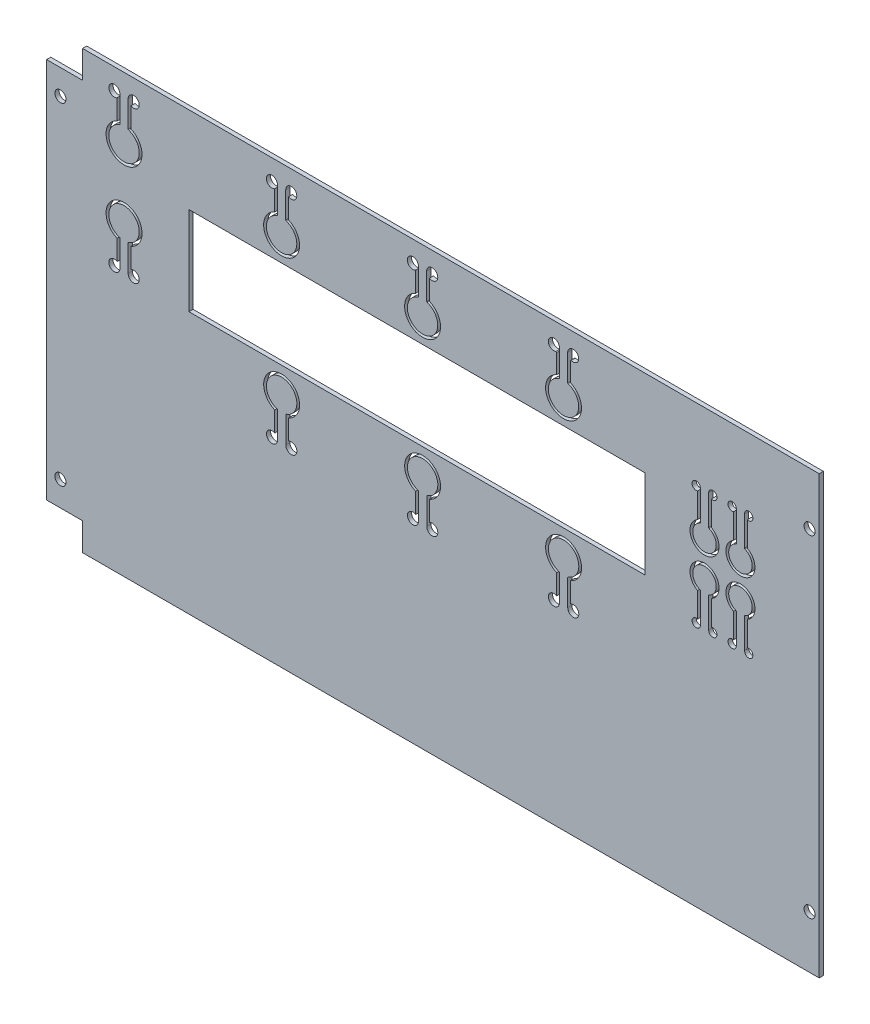
from build123d import *

# Parameters (mm, degrees)
RESSALTO_EXTRUS_O1_DEPTH = 1.5
CORTE_EXTRUS_O1_DEPTH    = 10
ESBO_O2_R                = 2
CORTE_EXTRUS_O2_DEPTH    = 2.5
FILETE1_R                = 0.25


with BuildPart() as part:
    # Model → Ressalto-extrusão1 (new body)
    with BuildSketch(Plane.XY):
        Polygon((22.046079585, 30.361653435), (22.058586918, 22.36166321), (288.058586918, 22.36166321), (288.058586918, 196.36166321), (22.058586918, 196.36166321), (22.058586918, 188.36166321), (12.058586918, 188.36166321), (12.058586918, 178.36166321), (4.058586918, 178.36166321), (4.058586918, 40.36166321), (12.058586918, 40.36166321), (12.046079585, 30.361671032), align=None)
        with BuildLine():
            ThreePointArc((35.057116656, 126.111663212), (31.325065848, 125.111663212), (34.057116656, 127.84371402))
            Line((34.057116656, 127.84371402), (34.057116656, 135.111663212))
            ThreePointArc((34.057116656, 135.111663212), (30.184182589, 142.390612542), (36.565672252, 147.611657582))
            ThreePointArc((36.565672252, 147.611657582), (42.94897806, 142.381529251), (39.057116656, 135.10456215))
            Line((39.057116656, 135.10456215), (39.057116656, 127.84371402))
            ThreePointArc((39.057116656, 127.84371402), (41.057116656, 127.84371402), (42.057116656, 126.111663212))
            ThreePointArc((42.057116656, 126.111663212), (40.057116656, 124.111663212), (38.057116656, 126.111663212))
            Line((38.057116656, 126.111663212), (38.057116656, 135.82016059))
            ThreePointArc((38.057116656, 135.82016059), (36.557116656, 146.611663212), (35.057116656, 135.82016059))
            Line((35.057116656, 135.82016059), (35.057116656, 126.111663212))
        make_face(mode=Mode.SUBTRACT)
        with BuildLine():
            Line((96.078534187, 109.861663212), (96.078534187, 102.59371402))
            ThreePointArc((96.078534187, 102.59371402), (98.078534187, 102.59371402), (99.078534187, 100.861663212))
            ThreePointArc((99.078534187, 100.861663212), (97.078534187, 98.861663212), (95.078534187, 100.861663212))
            Line((95.078534187, 100.861663212), (95.078534187, 110.57016059))
            ThreePointArc((95.078534187, 110.57016059), (93.578534187, 121.361663212), (92.078534187, 110.57016059))
            Line((92.078534187, 110.57016059), (92.078534187, 100.861663212))
            ThreePointArc((92.078534187, 100.861663212), (88.346483379, 99.861663212), (91.078534187, 102.59371402))
            Line((91.078534187, 102.59371402), (91.078534187, 109.861663212))
            ThreePointArc((91.078534187, 109.861663212), (93.578534187, 122.361663212), (96.078534187, 109.861663212))
        make_face(mode=Mode.SUBTRACT)
        with BuildLine():
            Line((147.078534187, 109.861663212), (147.078534187, 102.59371402))
            ThreePointArc((147.078534187, 102.59371402), (149.078534187, 102.59371402), (150.078534187, 100.861663212))
            ThreePointArc((150.078534187, 100.861663212), (148.078534187, 98.861663212), (146.078534187, 100.861663212))
            Line((146.078534187, 100.861663212), (146.078534187, 110.57016059))
            ThreePointArc((146.078534187, 110.57016059), (144.578534187, 121.361663212), (143.078534187, 110.57016059))
            Line((143.078534187, 110.57016059), (143.078534187, 100.861663212))
            ThreePointArc((143.078534187, 100.861663212), (139.346483379, 99.861663212), (142.078534187, 102.59371402))
            Line((142.078534187, 102.59371402), (142.078534187, 109.861663212))
            ThreePointArc((142.078534187, 109.861663212), (144.578534187, 122.361663212), (147.078534187, 109.861663212))
        make_face(mode=Mode.SUBTRACT)
        Polygon((225.058586918, 140.861663212), (225.058586918, 125.111663212), (60.058586918, 125.111663212), (60.058586918, 153.486663212), (60.058586918, 157.111663212), (225.058586918, 157.111663212), align=None, mode=Mode.SUBTRACT)
        with BuildLine():
            ThreePointArc((35.057116656, 171.153165835), (36.557116656, 160.361663212), (38.057116656, 171.153165835))
            Line((38.057116656, 171.153165835), (38.057116656, 180.861663212))
            ThreePointArc((38.057116656, 180.861663212), (40.057116656, 182.861663212), (42.057116656, 180.861663212))
            ThreePointArc((42.057116656, 180.861663212), (41.057116656, 179.129612405), (39.057116656, 179.129612405))
            Line((39.057116656, 179.129612405), (39.057116656, 171.861663212))
            ThreePointArc((39.057116656, 171.861663212), (36.557116656, 159.361663212), (34.057116656, 171.861663212))
            Line((34.057116656, 171.861663212), (34.057116656, 179.129612405))
            ThreePointArc((34.057116656, 179.129612405), (31.325065848, 181.861663212), (35.057116656, 180.861663212))
            Line((35.057116656, 180.861663212), (35.057116656, 171.153165835))
        make_face(mode=Mode.SUBTRACT)
        with BuildLine():
            Line((91.058586918, 171.861663212), (91.058586918, 179.129612405))
            ThreePointArc((91.058586918, 179.129612405), (88.32653611, 181.861663212), (92.058586918, 180.861663212))
            Line((92.058586918, 180.861663212), (92.058586918, 171.153165835))
            ThreePointArc((92.058586918, 171.153165835), (93.558586918, 160.361663212), (95.058586918, 171.153165835))
            Line((95.058586918, 171.153165835), (95.058586918, 180.861663212))
            ThreePointArc((95.058586918, 180.861663212), (97.057116656, 182.86019295), (99.055646393, 180.861663212))
            ThreePointArc((99.055646393, 180.861663212), (98.056749022, 179.131097916), (96.058586918, 179.130461469))
            Line((96.058586918, 179.130461469), (96.058586918, 171.861663212))
            ThreePointArc((96.058586918, 171.861663212), (93.558586918, 159.361663212), (91.058586918, 171.861663212))
        make_face(mode=Mode.SUBTRACT)
        with BuildLine():
            Line((143.057116656, 180.861663212), (143.057116656, 171.153165835))
            ThreePointArc((143.057116656, 171.153165835), (144.557116656, 160.361663212), (146.057116656, 171.153165835))
            Line((146.057116656, 171.153165835), (146.057116656, 180.861663212))
            ThreePointArc((146.057116656, 180.861663212), (148.057116656, 182.861663212), (150.057116656, 180.861663212))
            ThreePointArc((150.057116656, 180.861663212), (149.057116656, 179.129612405), (147.057116656, 179.129612405))
            Line((147.057116656, 179.129612405), (147.057116656, 171.861663212))
            ThreePointArc((147.057116656, 171.861663212), (144.557116656, 159.361663212), (142.057116656, 171.861663212))
            Line((142.057116656, 171.861663212), (142.057116656, 179.129612405))
            ThreePointArc((142.057116656, 179.129612405), (139.325065848, 181.861663212), (143.057116656, 180.861663212))
        make_face(mode=Mode.SUBTRACT)
        with BuildLine():
            Line((198.080004449, 109.861663212), (198.080004449, 102.59371402))
            ThreePointArc((198.080004449, 102.59371402), (200.080004449, 102.59371402), (201.080004449, 100.861663212))
            ThreePointArc((201.080004449, 100.861663212), (199.080004449, 98.861663212), (197.080004449, 100.861663212))
            Line((197.080004449, 100.861663212), (197.080004449, 110.57016059))
            ThreePointArc((197.080004449, 110.57016059), (195.580004449, 121.361663212), (194.080004449, 110.57016059))
            Line((194.080004449, 110.57016059), (194.080004449, 100.861663212))
            ThreePointArc((194.080004449, 100.861663212), (190.347953642, 99.861663212), (193.080004449, 102.59371402))
            Line((193.080004449, 102.59371402), (193.080004449, 109.861663212))
            ThreePointArc((193.080004449, 109.861663212), (195.580004449, 122.361663212), (198.080004449, 109.861663212))
        make_face(mode=Mode.SUBTRACT)
        with BuildLine():
            ThreePointArc((245.058586918, 119.361663212), (242.333842046, 118.495637809), (244.058586918, 120.775876775))
            Line((244.058586918, 120.775876775), (244.058586918, 129.745116884))
            ThreePointArc((244.058586918, 129.745116884), (246.558586918, 139.611663212), (249.058586918, 129.745116884))
            Line((249.058586918, 129.745116884), (249.058586918, 120.775876775))
            ThreePointArc((249.058586918, 120.775876775), (250.424612322, 120.586408084), (251.058586918, 119.361663212))
            ThreePointArc((251.058586918, 119.361663212), (249.558586918, 117.861663212), (248.058586918, 119.361663212))
            Line((248.058586918, 119.361663212), (248.058586918, 130.385169782))
            ThreePointArc((248.058586918, 130.385169782), (246.558586918, 138.611663212), (245.058586918, 130.385169782))
            Line((245.058586918, 130.385169782), (245.058586918, 119.361663212))
        make_face(mode=Mode.SUBTRACT)
        with BuildLine():
            ThreePointArc((261.025892133, 130.372989823), (259.558586918, 138.611663212), (258.091281703, 130.372989823))
            Line((258.091281703, 130.372989823), (258.091281703, 119.361663212))
            Line((258.091281703, 119.361663212), (258.058586918, 119.361663212))
            ThreePointArc((258.058586918, 119.361663212), (255.333842046, 118.495637809), (257.058586918, 120.775876775))
            Line((257.058586918, 120.775876775), (257.058586918, 129.745116884))
            ThreePointArc((257.058586918, 129.745116884), (259.558586918, 139.611663212), (262.058586918, 129.745116884))
            Line((262.058586918, 129.745116884), (262.058586918, 120.775876775))
            ThreePointArc((262.058586918, 120.775876775), (263.424612322, 120.586408084), (264.058586918, 119.361663212))
            ThreePointArc((264.058586918, 119.361663212), (262.514129182, 117.862322187), (261.061222238, 119.450539622))
            Line((261.061222238, 119.450539622), (261.025892133, 119.450539622))
            Line((261.025892133, 119.450539622), (261.025892133, 130.372989823))
        make_face(mode=Mode.SUBTRACT)
        with BuildLine():
            ThreePointArc((194.058586918, 171.153165835), (195.558586918, 160.361663212), (197.058586918, 171.153165835))
            Line((197.058586918, 171.153165835), (197.058586918, 180.861663212))
            ThreePointArc((197.058586918, 180.861663212), (199.058586918, 182.861663212), (201.058586918, 180.861663212))
            ThreePointArc((201.058586918, 180.861663212), (200.058586918, 179.129612405), (198.058586918, 179.129612405))
            Line((198.058586918, 179.129612405), (198.058586918, 171.861663212))
            ThreePointArc((198.058586918, 171.861663212), (195.558586918, 159.361663212), (193.058586918, 171.861663212))
            Line((193.058586918, 171.861663212), (193.058586918, 179.129612405))
            ThreePointArc((193.058586918, 179.129612405), (190.32653611, 181.861663212), (194.058586918, 180.861663212))
            Line((194.058586918, 180.861663212), (194.058586918, 171.153165835))
        make_face(mode=Mode.SUBTRACT)
        with BuildLine():
            ThreePointArc((245.058586918, 151.338156643), (246.558586918, 143.111663212), (248.058586918, 151.338156643))
            Line((248.058586918, 151.338156643), (248.058586918, 162.361663212))
            ThreePointArc((248.058586918, 162.361663212), (249.558586918, 163.861663212), (251.058586918, 162.361663212))
            ThreePointArc((251.058586918, 162.361663212), (250.424612322, 161.136918341), (249.058586918, 160.94744965))
            Line((249.058586918, 160.94744965), (249.058586918, 151.978209541))
            ThreePointArc((249.058586918, 151.978209541), (246.558586918, 142.111663212), (244.058586918, 151.978209541))
            Line((244.058586918, 151.978209541), (244.058586918, 160.94744965))
            ThreePointArc((244.058586918, 160.94744965), (242.333842046, 163.227688616), (245.058586918, 162.361663212))
            Line((245.058586918, 162.361663212), (245.058586918, 151.338156643))
        make_face(mode=Mode.SUBTRACT)
        with BuildLine():
            ThreePointArc((264.058586918, 162.361663212), (263.424612322, 161.136918341), (262.058586918, 160.94744965))
            Line((262.058586918, 160.94744965), (262.058586918, 151.978209541))
            ThreePointArc((262.058586918, 151.978209541), (259.558586918, 142.111663212), (257.058586918, 151.978209541))
            Line((257.058586918, 151.978209541), (257.058586918, 160.94744965))
            ThreePointArc((257.058586918, 160.94744965), (255.333842046, 163.227688616), (258.058586918, 162.361663212))
            Line((258.058586918, 162.361663212), (258.091281703, 162.361663212))
            Line((258.091281703, 162.361663212), (258.091281703, 151.350336602))
            ThreePointArc((258.091281703, 151.350336602), (259.558586918, 143.111663212), (261.025892133, 151.350336602))
            Line((261.025892133, 151.350336602), (261.025892133, 162.272786803))
            Line((261.025892133, 162.272786803), (261.061222238, 162.272786803))
            ThreePointArc((261.061222238, 162.272786803), (262.514129182, 163.861004238), (264.058586918, 162.361663212))
        make_face(mode=Mode.SUBTRACT)
    extrude(amount=RESSALTO_EXTRUS_O1_DEPTH)

    # Esboço1 → Corte-extrusão1 (cut)
    with BuildSketch(Plane(origin=(0, 0, 0), x_dir=(-1, 0, 0), z_dir=(0, 0, -1))):
        Polygon((-288.074227849, 188.36166321), (-21.558586918, 188.36166321), (-21.558586918, 178.36166321), (-8.558586918, 178.36166321), (-8.558586918, 40.36166321), (-21.558586918, 40.36166321), (-21.558586918, 30.36166321), (-288.074227849, 30.36166321), (-288.074227849, 22.36166321), (-4.058586918, 22.36166321), (-4.058586918, 196.36166321), (-288.074227849, 196.36166321), align=None)
    extrude(amount=-CORTE_EXTRUS_O1_DEPTH, mode=Mode.SUBTRACT)

    # Esboço2 → Corte-extrusão2 (cut, through all)
    with BuildSketch(Plane.XY.offset(1.5)):
        with Locations((284.558586918, 169.361663082)):
            Circle(ESBO_O2_R)
        with Locations((284.558586918, 49.361663082)):
            Circle(ESBO_O2_R)
        with Locations((13.558586918, 49.361823624)):
            Circle(ESBO_O2_R)
        with Locations((13.558586918, 169.361823624)):
            Circle(ESBO_O2_R)
    extrude(amount=-CORTE_EXTRUS_O2_DEPTH, mode=Mode.SUBTRACT)

    # Filete1
    filete1_edges = [part.edges().sort_by_distance(p)[0] for p in [
        (258.091281703, 151.350336602, 0.75),
        (261.025892133, 151.350336602, 0.75),
        (248.058586918, 151.338156643, 0.75),
        (245.058586918, 151.338156643, 0.75),
        (35.057116656, 135.82016059, 0.75),
        (38.057116656, 135.82016059, 0.75),
        (38.057116656, 171.153165835, 0.75),
        (35.057116656, 171.153165835, 0.75),
        (194.080004449, 110.57016059, 0.75),
        (197.080004449, 110.57016059, 0.75),
        (92.078534187, 110.57016059, 0.75),
        (95.078534187, 110.57016059, 0.75),
        (95.058586918, 171.153165835, 0.75),
        (92.058586918, 171.153165835, 0.75),
        (146.057116656, 171.153165835, 0.75),
        (143.057116656, 171.153165835, 0.75),
        (193.058586918, 179.129612405, 0.75),
        (198.058586918, 179.129612405, 0.75),
        (197.058586918, 171.153165835, 0.75),
        (194.058586918, 171.153165835, 0.75),
        (143.078534187, 110.57016059, 0.75),
        (146.078534187, 110.57016059, 0.75),
        (258.091281703, 130.372989823, 0.75),
        (261.025892133, 130.372989823, 0.75),
        (248.058586918, 130.385169782, 0.75),
        (245.058586918, 130.385169782, 0.75),
    ]]
    fillet(filete1_edges, radius=FILETE1_R)


solid = part.part
